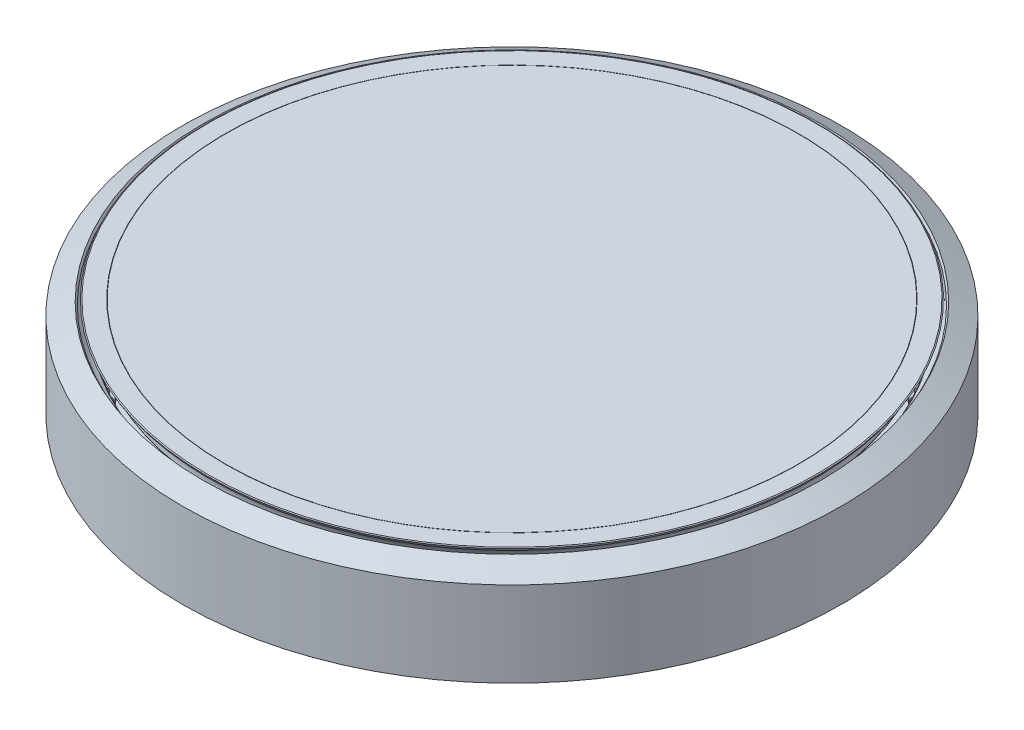
from build123d import *

# Parameters (mm, degrees)
BOSS_EXTRUDE1_DEPTH = 5
CIRPATTERN1_COUNT   = 100


with BuildPart() as part:
    # Sketch1 → Revolve1 (revolve)
    with BuildSketch(Plane.XY, mode=Mode.PRIVATE) as revolve1_sk:
        with BuildLine():
            Line((-107.366211493, 18.121345869), (-107.899038106, 19.044228634))
            Line((-107.899038106, 19.044228634), (-115.131088913, 14.868802154))
            Line((-115.131088913, 14.868802154), (-115.131088913, 0))
            Line((-115.131088913, 0), (-105.131088913, 0))
            Line((-105.131088913, 0), (-105.131088913, 10.25))
            Line((-105.131088913, 10.25), (-103.399038106, 11.25))
            Line((-103.399038106, 11.25), (-103.931864719, 12.172882765))
            ThreePointArc((-103.931864719, 12.172882765), (-106.73156986, 14.522114317), (-107.366211493, 18.121345869))
        make_face()
        with BuildLine():
            Line((-106.243593539, 20), (-106.6, 19.794228634))
            Line((-106.6, 19.794228634), (-106.067173387, 18.871345869))
            ThreePointArc((-106.067173387, 18.871345869), (-103.267468245, 16.522114317), (-102.632826613, 12.922882765))
            Line((-102.632826613, 12.922882765), (-102.1, 12))
            Line((-102.1, 12), (-98.1, 12))
            Line((-98.1, 12), (-98.1, 15))
            Line((-98.1, 15), (-100, 15))
            Line((-100, 15), (-100.1, 15))
            Line((-100.1, 15), (-100.1, 20))
            Line((-100.1, 20), (-106.243593539, 20))
        make_face()
    revolve(revolve1_sk.sketch.rotate(Axis((0, 37.153255054, 0), (0, -1, 0)), 270), axis=Axis((0, 37.153255054, 0), (0, -1, 0)))


with BuildPart() as body_2:
    # Sketch1_6 → Revolve2 (revolve)
    with BuildSketch(Plane.XY, mode=Mode.PRIVATE) as revolve2_sk:
        Polygon((-100, 20), (-100, 15), (-98.1, 15), (0, 15), (0, 20), align=None)
    revolve(revolve2_sk.sketch.rotate(Axis((0, 37.153255054, 0), (0, -1, 0)), 270), axis=Axis((0, 37.153255054, 0), (0, -1, 0)))


with BuildPart() as body_3:
    # Mirror3: mirrored copy
    add(part.part.mirror(Plane.ZX))


with BuildPart() as body_4:
    # Mirror3 2: mirrored copy
    add(body_2.part.mirror(Plane.ZX))


with BuildPart() as part_1:
    add(part.part)

    # Combine2: union body 3
    add(body_3.part)

    # Sketch2 → Boss-Extrude1 (add, symmetric)
    with BuildSketch(Plane(origin=(0, 0, 0), x_dir=(1, 0, 0), z_dir=(0, 1, 0))):
        with BuildLine():
            Line((-2.313958486, 105.10562046), (-1.122764003, 100.828092914))
            Line((-1.122764003, 100.828092914), (1.122764003, 100.828092914))
            Line((1.122764003, 100.828092914), (2.313958486, 105.10562046))
            ThreePointArc((2.313958486, 105.10562046), (0, 105.131088913), (-2.313958486, 105.10562046))
        make_face()
    boss_extrude1 = extrude(amount=BOSS_EXTRUDE1_DEPTH, both=True)

    # CirPattern1: Boss-Extrude1 ×100 about axis
    cirpattern1_axis = Axis((0, 0, 0), (0, 1, 0))
    for i in range(1, CIRPATTERN1_COUNT):
        add(boss_extrude1.rotate(cirpattern1_axis, i * 360 / CIRPATTERN1_COUNT))


solid = Compound([body_2.part, body_4.part, part_1.part])
